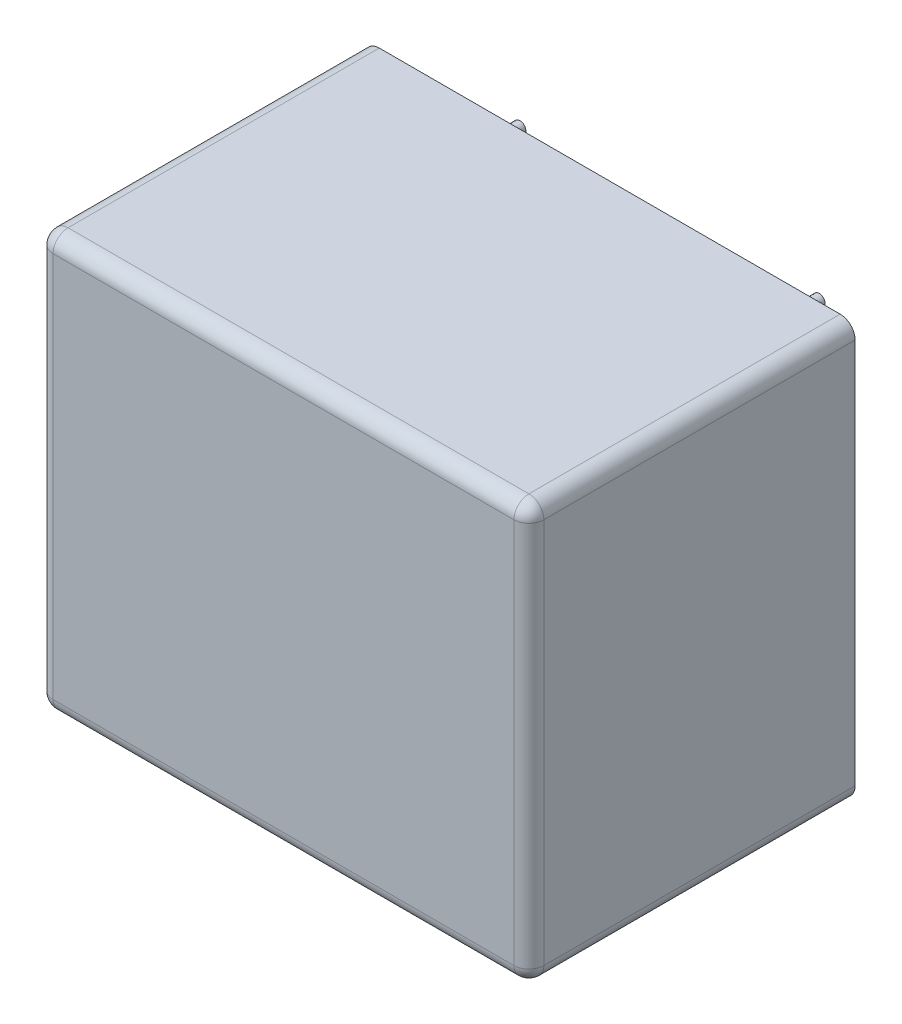
from build123d import *

# Parameters (mm, degrees)
P_IDAT_VYSUNUT_M1_DEPTH = 21.8
ZAOBLIT1_R              = 1
SKICA2_R                = 0.4
P_IDAT_VYSUNUT_M2_DEPTH = 4


with BuildPart() as part:
    # Skica1 → Přidat vysunutím1 (new body)
    with BuildSketch(Plane.XY):
        with BuildLine():
            Line((1, 0), (31.8, 0))
            ThreePointArc((31.8, 0), (32.507106781, 0.292893219), (32.8, 1))
            Line((32.8, 1), (32.8, 26.8))
            ThreePointArc((32.8, 26.8), (32.507106781, 27.507106781), (31.8, 27.8))
            Line((31.8, 27.8), (1, 27.8))
            ThreePointArc((1, 27.8), (0.292893219, 27.507106781), (0, 26.8))
            Line((0, 26.8), (0, 1))
            ThreePointArc((0, 1), (0.292893219, 0.292893219), (1, 0))
        make_face()
    extrude(amount=P_IDAT_VYSUNUT_M1_DEPTH)

    # Zaoblit1
    zaoblit1_edges = [part.edges().sort_by_distance(p)[0] for p in [
        (32.507106781, 27.507106781, 21.8),
        (16.4, 27.8, 21.8),
        (0.292893219, 27.507106781, 21.8),
        (0, 13.9, 21.8),
        (0.292893219, 0.292893219, 21.8),
        (16.4, 0, 21.8),
        (32.507106781, 0.292893219, 21.8),
        (32.8, 13.9, 21.8),
    ]]
    fillet(zaoblit1_edges, radius=ZAOBLIT1_R)

    # Skica2 → Přidat vysunutím2 (add)
    with BuildSketch(Plane.XY):
        with Locations((21.4, 3.9)):
            Circle(SKICA2_R)
        with Locations((26.4, 23.9)):
            Circle(SKICA2_R)
        with Locations((6.4, 23.9)):
            Circle(SKICA2_R)
        with Locations((11.4, 3.9)):
            Circle(SKICA2_R)
    extrude(amount=-P_IDAT_VYSUNUT_M2_DEPTH)


solid = part.part
